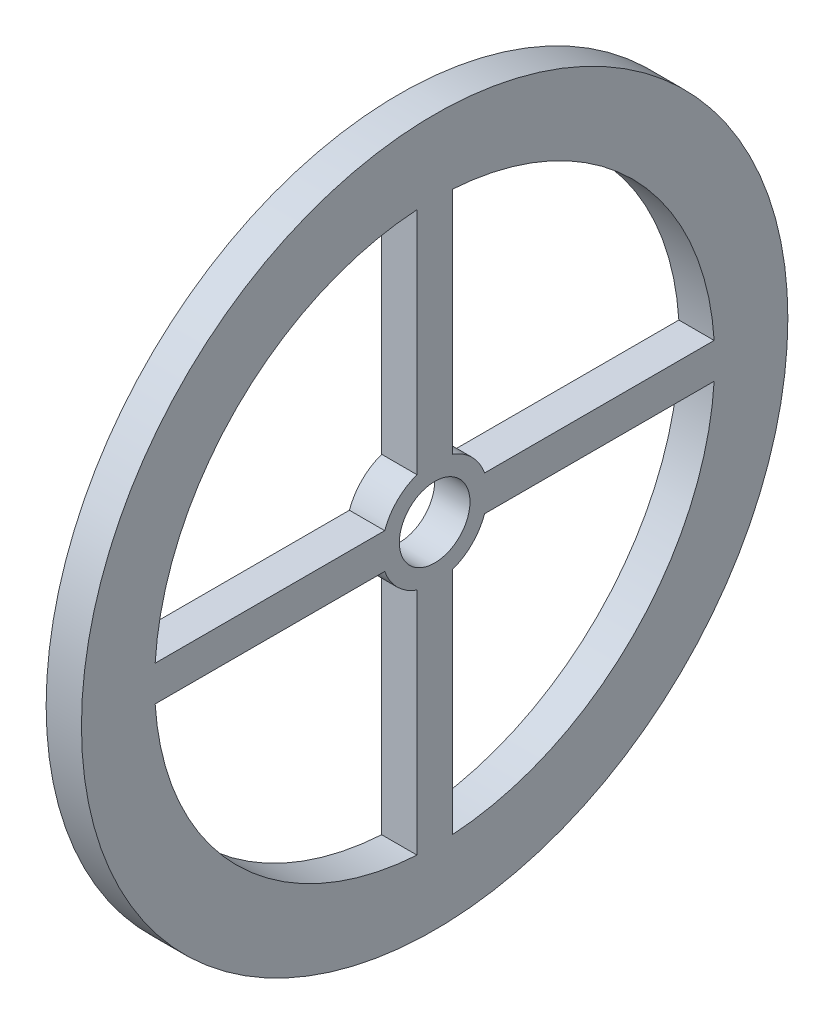
from build123d import *

# Parameters (mm, degrees)
SKETCH1_R           = 100
SKETCH1_R_2         = 79.286499618
SKETCH1_R_3         = 15
SKETCH1_R_4         = 10
BOSS_EXTRUDE1_DEPTH = 10


with BuildPart() as part:
    # Sketch1 → Boss-Extrude1 (new body)
    with BuildSketch(Plane(origin=(0, 0, 0), x_dir=(0, 0, -1), z_dir=(1, 0, 0))):
        Circle(SKETCH1_R)
        Circle(SKETCH1_R_2, mode=Mode.SUBTRACT)
        with BuildLine():
            Line((-5, -14.142135624), (-5, -79.128686465))
            ThreePointArc((-5, -79.128686465), (0, -79.286499618), (5, -79.128686465))
            Line((5, -79.128686465), (5, -14.142135624))
            ThreePointArc((5, -14.142135624), (0, -15), (-5, -14.142135624))
        make_face()
        with BuildLine():
            Line((-14.142135624, 5), (-79.128686465, 5))
            ThreePointArc((-79.128686465, 5), (-79.286499618, 0), (-79.128686465, -5))
            Line((-79.128686465, -5), (-14.142135624, -5))
            ThreePointArc((-14.142135624, -5), (-15, 0), (-14.142135624, 5))
        make_face()
        with BuildLine():
            ThreePointArc((5, 79.128686465), (0, 79.286499618), (-5, 79.128686465))
            Line((-5, 79.128686465), (-5, 14.142135624))
            ThreePointArc((-5, 14.142135624), (0, 15), (5, 14.142135624))
            Line((5, 14.142135624), (5, 79.128686465))
        make_face()
        with BuildLine():
            ThreePointArc((79.286499618, 0), (79.247036509, 2.50124494), (79.128686465, 5))
            Line((79.128686465, 5), (14.142135624, 5))
            ThreePointArc((14.142135624, 5), (14.783978395, 2.536529681), (15, 0))
            ThreePointArc((15, 0), (14.783978395, -2.536529681), (14.142135624, -5))
            Line((14.142135624, -5), (79.128686465, -5))
            ThreePointArc((79.128686465, -5), (79.247036509, -2.50124494), (79.286499618, 0))
        make_face()
        Circle(SKETCH1_R_3)
        Circle(SKETCH1_R_4, mode=Mode.SUBTRACT)
    extrude(amount=BOSS_EXTRUDE1_DEPTH)


solid = part.part
